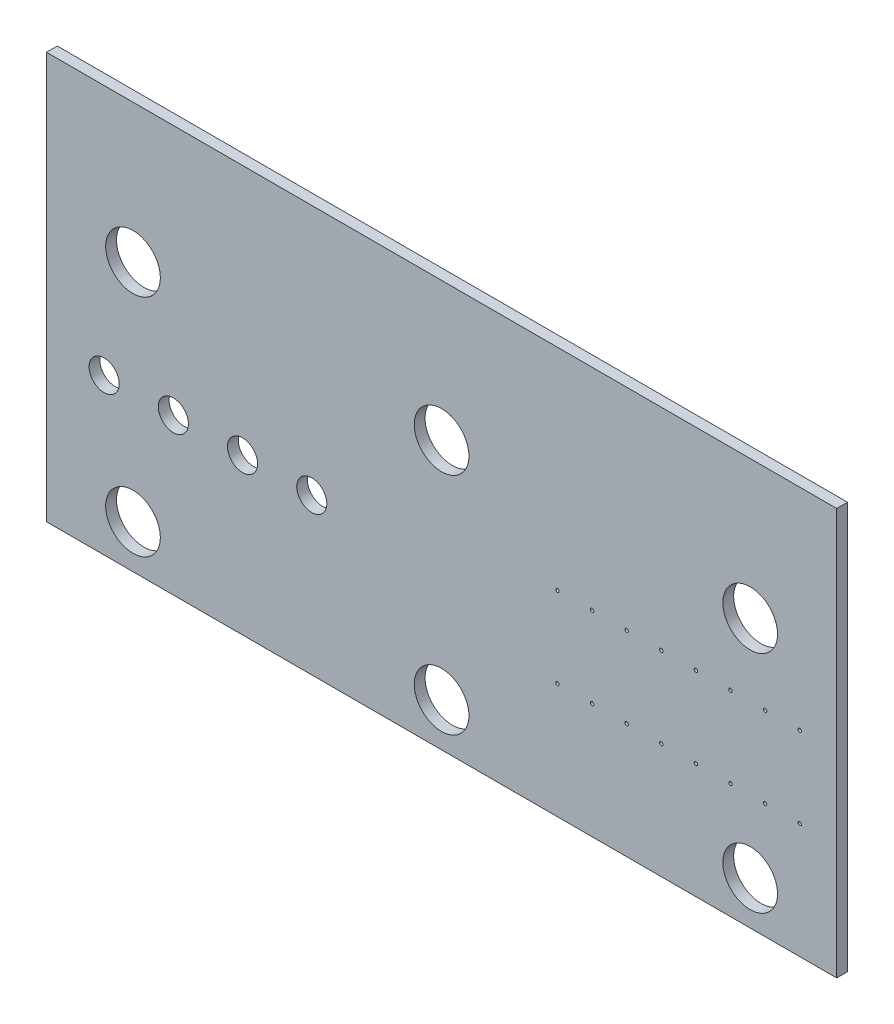
from build123d import *

# Parameters (mm, degrees)
SKETCH31_W     = 57.9999856
SKETCH31_H     = 29.845
SKETCH31_R     = 2.0066
SKETCH31_R_2   = 1.1049
SKETCH31_R_3   = 0.127
EXTRUDE2_DEPTH = 0.79375


with BuildPart() as part:
    # Sketch31 → Extrude2 (new body)
    with BuildSketch(Plane.XY):
        with Locations((103.5214084, 98.679127)):
            Rectangle(SKETCH31_W, SKETCH31_H)
        with Locations((80.8714156, 103.441627)):
            Circle(SKETCH31_R, mode=Mode.SUBTRACT)
        with Locations((103.5214084, 103.441627)):
            Circle(SKETCH31_R, mode=Mode.SUBTRACT)
        with Locations((126.1714012, 103.441627)):
            Circle(SKETCH31_R, mode=Mode.SUBTRACT)
        with Locations((80.8714156, 86.931627)):
            Circle(SKETCH31_R, mode=Mode.SUBTRACT)
        with Locations((103.5214084, 86.931627)):
            Circle(SKETCH31_R, mode=Mode.SUBTRACT)
        with Locations((126.1714012, 86.931627)):
            Circle(SKETCH31_R, mode=Mode.SUBTRACT)
        with Locations((78.7523952, 95.1825884)):
            Circle(SKETCH31_R_2, mode=Mode.SUBTRACT)
        with Locations((83.8323952, 95.1825884)):
            Circle(SKETCH31_R_2, mode=Mode.SUBTRACT)
        with Locations((88.9123952, 95.1825884)):
            Circle(SKETCH31_R_2, mode=Mode.SUBTRACT)
        with Locations((93.9923952, 95.1825884)):
            Circle(SKETCH31_R_2, mode=Mode.SUBTRACT)
        with Locations((112.026446, 98.1459302)):
            Circle(SKETCH31_R_3, mode=Mode.SUBTRACT)
        with Locations((114.566446, 98.1459302)):
            Circle(SKETCH31_R_3, mode=Mode.SUBTRACT)
        with Locations((117.106446, 98.1459302)):
            Circle(SKETCH31_R_3, mode=Mode.SUBTRACT)
        with Locations((119.646446, 98.1459302)):
            Circle(SKETCH31_R_3, mode=Mode.SUBTRACT)
        with Locations((122.186446, 98.1459302)):
            Circle(SKETCH31_R_3, mode=Mode.SUBTRACT)
        with Locations((124.726446, 98.1459302)):
            Circle(SKETCH31_R_3, mode=Mode.SUBTRACT)
        with Locations((127.266446, 98.1459302)):
            Circle(SKETCH31_R_3, mode=Mode.SUBTRACT)
        with Locations((129.806446, 98.1459302)):
            Circle(SKETCH31_R_3, mode=Mode.SUBTRACT)
        with Locations((112.026446, 92.219272)):
            Circle(SKETCH31_R_3, mode=Mode.SUBTRACT)
        with Locations((114.566446, 92.219272)):
            Circle(SKETCH31_R_3, mode=Mode.SUBTRACT)
        with Locations((117.106446, 92.219272)):
            Circle(SKETCH31_R_3, mode=Mode.SUBTRACT)
        with Locations((119.646446, 92.219272)):
            Circle(SKETCH31_R_3, mode=Mode.SUBTRACT)
        with Locations((122.186446, 92.219272)):
            Circle(SKETCH31_R_3, mode=Mode.SUBTRACT)
        with Locations((124.726446, 92.219272)):
            Circle(SKETCH31_R_3, mode=Mode.SUBTRACT)
        with Locations((127.266446, 92.219272)):
            Circle(SKETCH31_R_3, mode=Mode.SUBTRACT)
        with Locations((129.806446, 92.219272)):
            Circle(SKETCH31_R_3, mode=Mode.SUBTRACT)
    extrude(amount=EXTRUDE2_DEPTH)


solid = part.part
